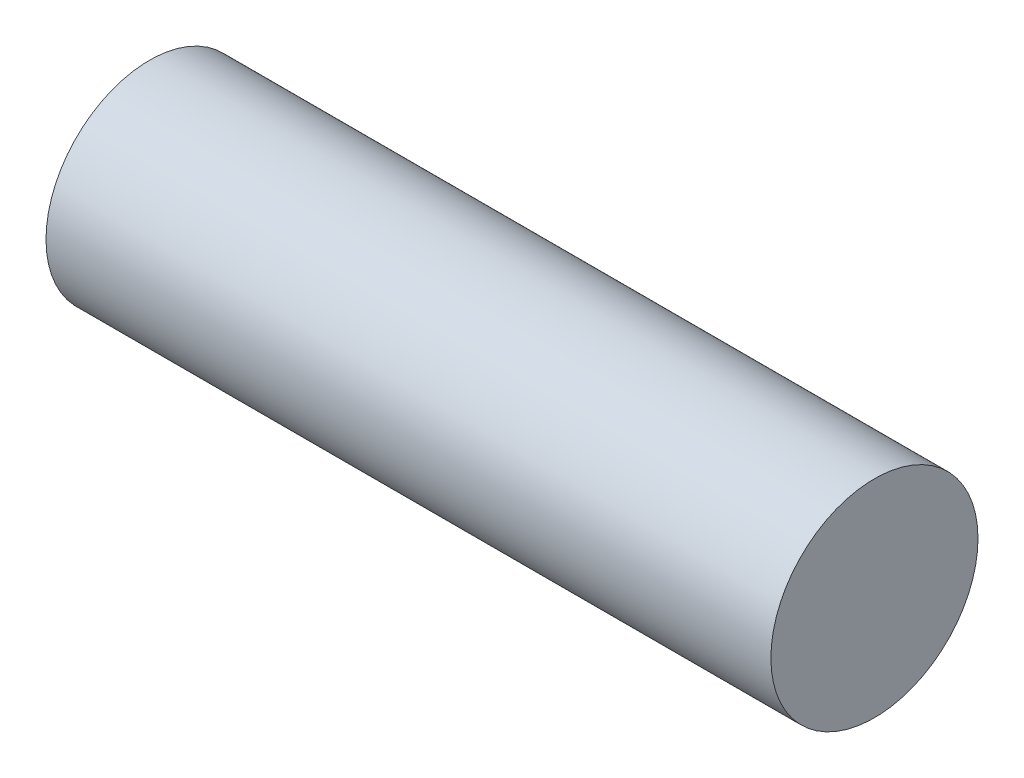
from build123d import *

# Parameters (mm, degrees)
SKETCH1_R           = 10
BOSS_EXTRUDE1_DEPTH = 70


with BuildPart() as part:
    # Sketch1 → Boss-Extrude1 (new body)
    with BuildSketch(Plane(origin=(0, 0, 0), x_dir=(0, 0, -1), z_dir=(1, 0, 0))):
        Circle(SKETCH1_R)
    extrude(amount=BOSS_EXTRUDE1_DEPTH)


solid = part.part
